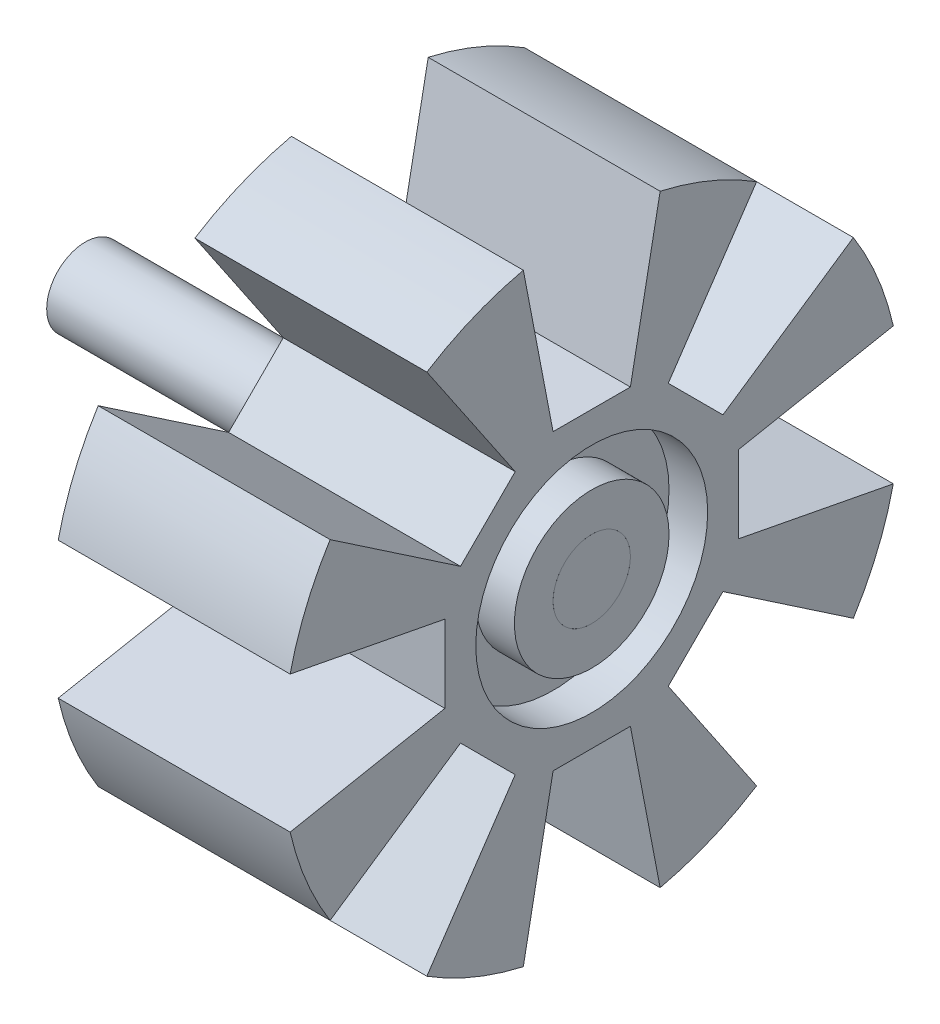
from build123d import *

# Parameters (mm, degrees)
CUT_EXTRUDE6_DEPTH       = 31
CIRPATTERN6_COUNT        = 8
SKETCH9_R                = 5
BOSS_EXTRUDE1_DEPTH      = 35.5
BOSS_EXTRUDE1_DEPTH_BACK = 30
SKETCH11_R               = 2.95
CUT_EXTRUDE7_DEPTH       = 15.5


with BuildPart() as part:
    # Sketch2 → Revolve1 (revolve)
    with BuildSketch(Plane.XY):
        Polygon((0, 5), (-30, 5), (-30, 10), (-25, 10), (-25, 15), (-30, 15), (-30, 40), (0, 40), (0, 15), (-5, 15), (-5, 10), (0, 10), align=None)
    revolve(axis=Axis((0, 0, 0), (-1, 0, 0)))

    # Sketch8 → Cut-Extrude6 (cut, through all)
    with BuildSketch(Plane.ZY.offset(30)):
        Polygon((-10, 45), (10, 45), (5, 19), (-5, 19), align=None)
    cut_extrude6 = extrude(amount=-CUT_EXTRUDE6_DEPTH, mode=Mode.SUBTRACT)

    # CirPattern6: Cut-Extrude6 ×8 about axis
    cirpattern6_axis = Axis((0, 0, 0), (1, 0, 0))
    for i in range(1, CIRPATTERN6_COUNT):
        add(cut_extrude6.rotate(cirpattern6_axis, i * 360 / CIRPATTERN6_COUNT), mode=Mode.SUBTRACT)


with BuildPart() as body_2:
    # Sketch9 → Boss-Extrude1 (new body, two sides)
    with BuildSketch(Plane.ZY.offset(30)) as boss_extrude1_sk:
        Circle(SKETCH9_R)
    extrude(amount=BOSS_EXTRUDE1_DEPTH)
    extrude(boss_extrude1_sk.sketch, amount=-BOSS_EXTRUDE1_DEPTH_BACK)

    # Sketch11 → Cut-Extrude7 (cut)
    with BuildSketch(Plane.ZY.offset(65.5)):
        Circle(SKETCH11_R)
    extrude(amount=-CUT_EXTRUDE7_DEPTH, mode=Mode.SUBTRACT)


solid = Compound([part.part, body_2.part])
